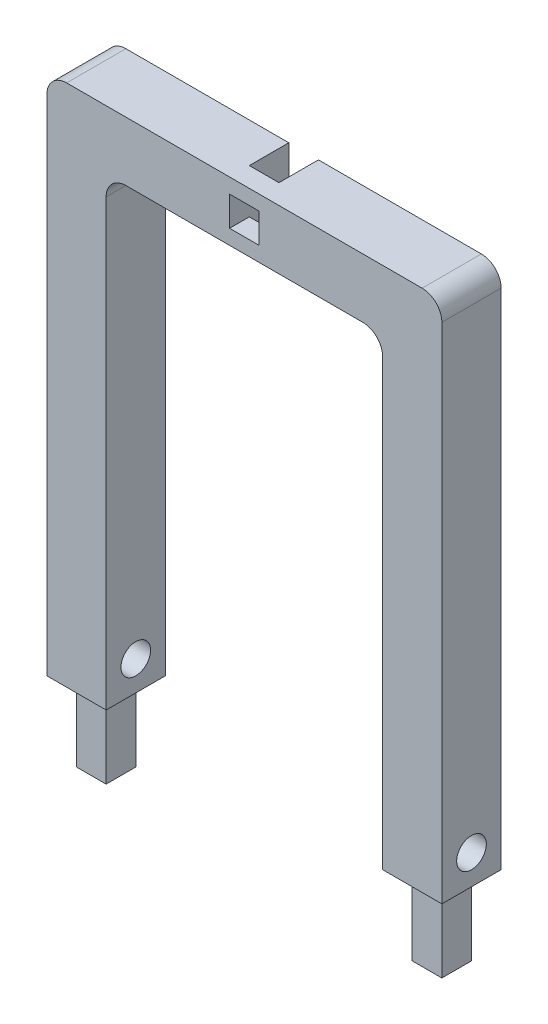
from build123d import *

# Parameters (mm, degrees)
BOSS_EXTRUDE1_DEPTH     = 30
SKETCH2_W               = 15
SKETCH2_H               = 15
BOSS_EXTRUDE2_DEPTH     = 40
FILLET1_R               = 10
FILLET2_R               = 10
SKETCH3_R               = 7.5
CUT_EXTRUDE1_DEPTH      = 171
CUT_EXTRUDE1_DEPTH_BACK = 31
SKETCH4_W               = 15
SKETCH4_H               = 30
CUT_EXTRUDE2_DEPTH      = 20
SKETCH5_W               = 15
SKETCH5_H               = 15
CUT_EXTRUDE3_DEPTH      = 10


with BuildPart() as part:
    # Sketch1 → Boss-Extrude1 (new body)
    with BuildSketch(Plane.XY):
        Polygon((-77.931034483, -87.881800857), (-107.931034483, -87.881800857), (-107.931034483, 177.118199143), (92.068965517, 177.118199143), (92.068965517, -87.881800857), (62.068965517, -87.881800857), (62.068965517, 147.118199143), (-77.931034483, 147.118199143), align=None)
    extrude(amount=BOSS_EXTRUDE1_DEPTH)

    # Sketch2 → Boss-Extrude2 (add)
    with BuildSketch(Plane.XZ.offset(87.881800857)):
        with Locations((77.068965517, 15)):
            Rectangle(SKETCH2_W, SKETCH2_H)
        with Locations((-92.931034483, 15)):
            Rectangle(SKETCH2_W, SKETCH2_H)
    extrude(amount=BOSS_EXTRUDE2_DEPTH)

    # Fillet1
    fillet1_edges = [part.edges().sort_by_distance(p)[0] for p in [
        (62.068965517, 147.118199143, 15),
        (-77.931034483, 147.118199143, 15),
    ]]
    fillet(fillet1_edges, radius=FILLET1_R)

    # Fillet2
    fillet2_edges = [part.edges().sort_by_distance(p)[0] for p in [
        (-107.931034483, 177.118199143, 15),
        (92.068965517, 177.118199143, 15),
    ]]
    fillet(fillet2_edges, radius=FILLET2_R)

    # Sketch3 → Cut-Extrude1 (cut, two sides)
    with BuildSketch(Plane(origin=(-77.931034483, 0, 0), x_dir=(0, 0, -1), z_dir=(1, 0, 0))) as cut_extrude1_sk:
        with Locations((-15, -72.881800857)):
            Circle(SKETCH3_R)
    extrude(amount=CUT_EXTRUDE1_DEPTH, mode=Mode.SUBTRACT)
    extrude(cut_extrude1_sk.sketch, amount=-CUT_EXTRUDE1_DEPTH_BACK, mode=Mode.SUBTRACT)

    # Sketch4 → Cut-Extrude2 (cut)
    with BuildSketch(Plane(origin=(0, 0, 0), x_dir=(-1, 0, 0), z_dir=(0, 0, -1))):
        with Locations((7.930867489, 162.118199143)):
            Rectangle(SKETCH4_W, SKETCH4_H)
    extrude(amount=-CUT_EXTRUDE2_DEPTH, mode=Mode.SUBTRACT)

    # Sketch5 → Cut-Extrude3 (cut)
    with BuildSketch(Plane.XY.offset(30)):
        with Locations((-7.930867489, 162.118199143)):
            Rectangle(SKETCH5_W, SKETCH5_H)
    extrude(amount=-CUT_EXTRUDE3_DEPTH, mode=Mode.SUBTRACT)


solid = part.part
